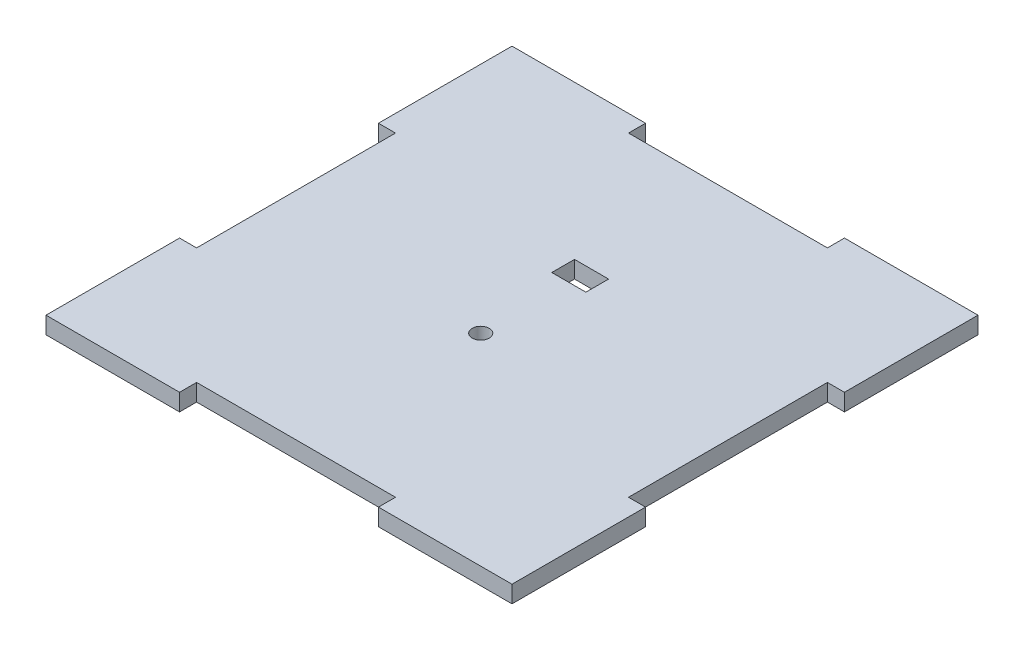
from build123d import *

# Parameters (mm, degrees)
BOSS_EXTRUDE1_DEPTH = 3
SKETCH2_R           = 1.5
SKETCH2_W           = 6
SKETCH2_H           = 4
CUT_EXTRUDE1_DEPTH  = 3


with BuildPart() as part:
    # Sketch1 → Boss-Extrude1 (new body)
    with BuildSketch(Plane(origin=(0, 0, 0), x_dir=(1, 0, 0), z_dir=(0, 1, 0))):
        Polygon((-41, -41), (-17.5, -41), (-17.5, -38), (17.5, -38), (17.5, -41), (41, -41), (41, -17.5), (38, -17.5), (38, 17.5), (41, 17.5), (41, 41), (17.5, 41), (17.5, 38), (-17.5, 38), (-17.5, 41), (-41, 41), (-41, 17.5), (-38, 17.5), (-38, -17.5), (-41, -17.5), align=None)
    extrude(amount=BOSS_EXTRUDE1_DEPTH)

    # Sketch2 → Cut-Extrude1 (cut)
    with BuildSketch(Plane(origin=(0, 3, 0), x_dir=(1, 0, 0), z_dir=(0, 1, 0))):
        with Locations((0, -5.5)):
            Circle(SKETCH2_R)
        with Locations((0, 12)):
            Rectangle(SKETCH2_W, SKETCH2_H)
    extrude(amount=-CUT_EXTRUDE1_DEPTH, mode=Mode.SUBTRACT)


solid = part.part
